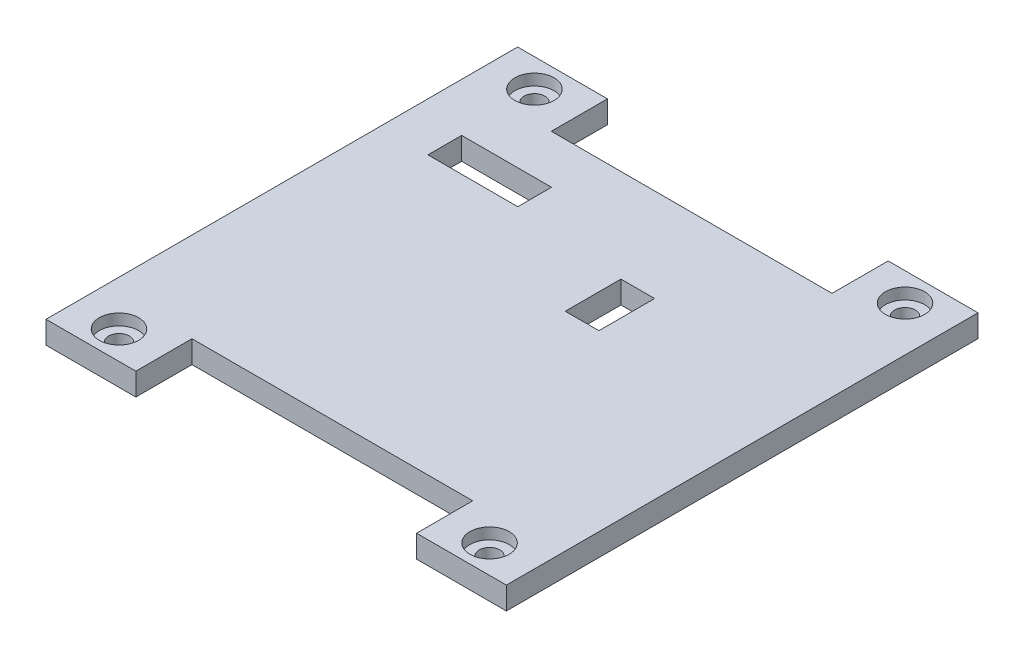
from build123d import *

# Parameters (mm, degrees)
SKETCH1_W           = 35
SKETCH1_H           = 26
BOSS_EXTRUDE1_DEPTH = 2
SKETCH2_W           = 41
SKETCH2_H           = 32
BOSS_EXTRUDE3_DEPTH = 2
SKETCH4_W           = 8
SKETCH4_H           = 2
BOSS_EXTRUDE4_DEPTH = 5
SKETCH5_W           = 8
SKETCH5_H           = 2
BOSS_EXTRUDE5_DEPTH = 5
SKETCH6_R           = 0.925
CUT_EXTRUDE1_DEPTH  = 5
SKETCH7_R           = 1.75
CUT_EXTRUDE2_DEPTH  = 1
SKETCH8_W           = 3
SKETCH8_H           = 5
BOSS_EXTRUDE6_DEPTH = 1.2
SKETCH9_W           = 3
SKETCH9_H           = 4.959490372
SKETCH9_W_2         = 8
SKETCH9_H_2         = 3
CUT_EXTRUDE3_DEPTH  = 2


with BuildPart() as part:
    # Sketch1 → Boss-Extrude1 (new body)
    with BuildSketch(Plane(origin=(0, 0, 0), x_dir=(1, 0, 0), z_dir=(0, 1, 0))):
        with Locations((4.316901408, -0.671361502)):
            Rectangle(SKETCH1_W, SKETCH1_H)
    extrude(amount=BOSS_EXTRUDE1_DEPTH)

    # Sketch2 → Boss-Extrude3 (add)
    with BuildSketch(Plane(origin=(0, 2, 0), x_dir=(1, 0, 0), z_dir=(0, 1, 0))):
        with Locations((4.316901408, -0.671361502)):
            Rectangle(SKETCH2_W, SKETCH2_H)
    extrude(amount=-BOSS_EXTRUDE3_DEPTH)

    # Sketch4 → Boss-Extrude4 (add)
    with BuildSketch(Plane(origin=(0, 0, -15.328638498), x_dir=(-1, 0, 0), z_dir=(0, 0, -1))):
        with Locations((12.183098592, 1)):
            Rectangle(SKETCH4_W, SKETCH4_H)
        with Locations((-20.816901408, 1)):
            Rectangle(SKETCH4_W, SKETCH4_H)
    extrude(amount=BOSS_EXTRUDE4_DEPTH)

    # Sketch5 → Boss-Extrude5 (add)
    with BuildSketch(Plane.XY.offset(16.671361502)):
        with Locations((20.816901408, 1)):
            Rectangle(SKETCH5_W, SKETCH5_H)
        with Locations((-12.183098592, 1)):
            Rectangle(SKETCH5_W, SKETCH5_H)
    extrude(amount=BOSS_EXTRUDE5_DEPTH)

    # Sketch6 → Cut-Extrude1 (cut)
    with BuildSketch(Plane(origin=(0, 2, 0), x_dir=(1, 0, 0), z_dir=(0, 1, 0))):
        with Locations((-12.183098592, 17.828638498)):
            Circle(SKETCH6_R)
        with Locations((20.816901408, 17.828638498)):
            Circle(SKETCH6_R)
        with Locations((20.816901408, -19.171361502)):
            Circle(SKETCH6_R)
        with Locations((-12.183098592, -19.171361502)):
            Circle(SKETCH6_R)
    extrude(amount=-CUT_EXTRUDE1_DEPTH, mode=Mode.SUBTRACT)

    # Sketch7 → Cut-Extrude2 (cut)
    with BuildSketch(Plane(origin=(0, 2, 0), x_dir=(1, 0, 0), z_dir=(0, 1, 0))):
        with Locations((-12.183098592, 17.828638498)):
            Circle(SKETCH7_R)
        with Locations((20.816901408, 17.828638498)):
            Circle(SKETCH7_R)
        with Locations((20.816901408, -19.171361502)):
            Circle(SKETCH7_R)
        with Locations((-12.183098592, -19.171361502)):
            Circle(SKETCH7_R)
    extrude(amount=-CUT_EXTRUDE2_DEPTH, mode=Mode.SUBTRACT)

    # Sketch8 → Boss-Extrude6 (add)
    with BuildSketch(Plane.XZ):
        with Locations((10.816901408, -4.528382577)):
            Rectangle(SKETCH8_W, SKETCH8_H)
    extrude(amount=BOSS_EXTRUDE6_DEPTH)

    # Sketch9 → Cut-Extrude3 (cut)
    with BuildSketch(Plane.XZ):
        with Locations((7.816901408, -4.548637391)):
            Rectangle(SKETCH9_W, SKETCH9_H)
        with Locations((-7.857851807, -9.519264119)):
            Rectangle(SKETCH9_W_2, SKETCH9_H_2)
    extrude(amount=-CUT_EXTRUDE3_DEPTH, mode=Mode.SUBTRACT)


solid = part.part
